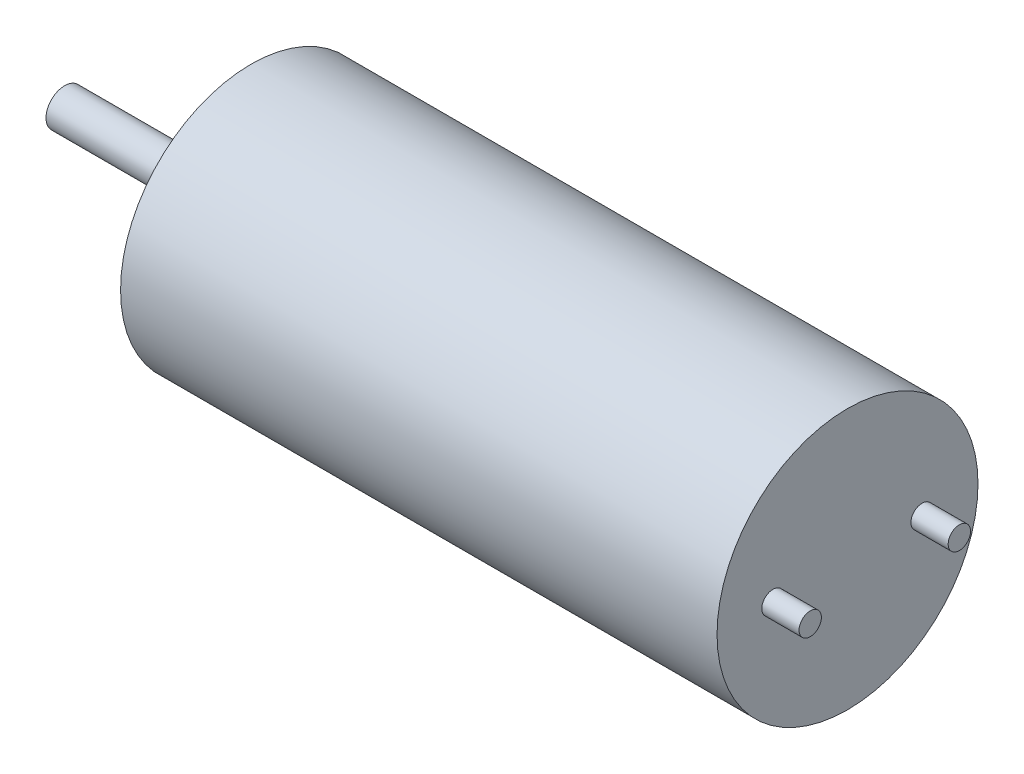
from build123d import *

# Parameters (mm, degrees)
SKETCH1_R           = 3.5
BOSS_EXTRUDE1_DEPTH = 16
SKETCH2_R           = 1.2
BOSS_EXTRUDE2_DEPTH = 0.8
SKETCH3_R           = 0.5
BOSS_EXTRUDE3_DEPTH = 4.2
SKETCH4_R           = 0.3
BOSS_EXTRUDE4_DEPTH = 1


with BuildPart() as part:
    # Sketch1 → Boss-Extrude1 (new body)
    with BuildSketch(Plane(origin=(0, 0, 0), x_dir=(0, 0, -1), z_dir=(1, 0, 0))):
        Circle(SKETCH1_R)
    extrude(amount=BOSS_EXTRUDE1_DEPTH)

    # Sketch2 → Boss-Extrude2 (add)
    with BuildSketch(Plane.ZY):
        Circle(SKETCH2_R)
    extrude(amount=BOSS_EXTRUDE2_DEPTH)

    # Sketch3 → Boss-Extrude3 (add)
    with BuildSketch(Plane.ZY.offset(0.8)):
        Circle(SKETCH3_R)
    extrude(amount=BOSS_EXTRUDE3_DEPTH)

    # Sketch4 → Boss-Extrude4 (add)
    with BuildSketch(Plane(origin=(16, 0, 0), x_dir=(0, 0, -1), z_dir=(1, 0, 0))):
        with Locations((-2, 0)):
            Circle(SKETCH4_R)
        with Locations((2, 0)):
            Circle(SKETCH4_R)
    extrude(amount=BOSS_EXTRUDE4_DEPTH)


solid = part.part
